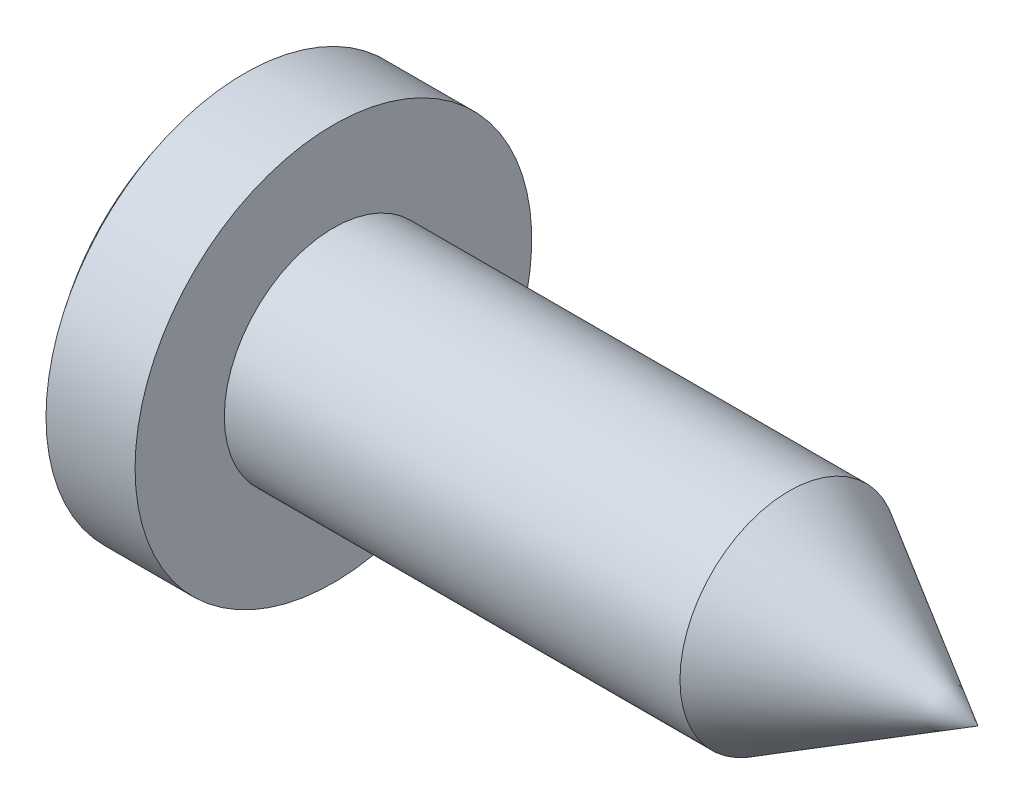
from build123d import *

# Parameters (mm, degrees)
CHAMFER1_SIZE      = 0.22
CHAMFER1_SIZE2     = 0.381051178
CUT_EXTRUDE1_DEPTH = 0.85
CUT_EXTRUDE1_TAPER = 6


with BuildPart() as part:
    # Sketch1 → Revolve1 (revolve)
    with BuildSketch(Plane.XY):
        with BuildLine():
            Line((0, 2), (-0.897999199, 2))
            ThreePointArc((-0.897999199, 2), (-1.419403703, 1.059811908), (-1.6, 0))
            Line((-1.6, 0), (6.5, 0))
            Line((6.5, 0), (6.5, 1.1))
            Line((6.5, 1.1), (0, 1.1))
            Line((0, 1.1), (0, 2))
        make_face()
    revolve(axis=Axis((0, 0, 0), (1, 0, 0)))

    # Chamfer1
    chamfer1_edges = [part.edges().sort_by_distance(p)[0] for p in [
        (6.5, -1.1, 0),
    ]]
    chamfer1_side = [part.faces().sort_by_distance(p)[0] for p in [
        (6.5, 0, 0),
    ]]
    chamfer(chamfer1_edges, length=CHAMFER1_SIZE, length2=CHAMFER1_SIZE2, reference=chamfer1_side[0])

    # Sketch2 → EndCone (revolve, cut)
    with BuildSketch(Plane.XY):
        Polygon((6.5, 0), (4.594744112, 1.1), (4.594744112, 1.2), (6.6, 1.2), (6.6, 0), align=None)
    revolve(axis=Axis((0, 0, 0), (1, 0, 0)), mode=Mode.SUBTRACT)

    # Sketch3 → Cut-Extrude1 (cut)
    with BuildSketch(Plane(origin=(-1.6, 0, 0), x_dir=(0, 0, -1), z_dir=(1, 0, 0))):
        Polygon((-0.2375, 0.95), (-0.1425, 0.57), (-0.29897586, 0.29897586), (-0.57, 0.1425), (-0.95, 0.2375), (-0.95, -0.2375), (-0.57, -0.1425), (-0.29897586, -0.29897586), (-0.1425, -0.57), (-0.2375, -0.95), (0.2375, -0.95), (0.1425, -0.57), (0.29897586, -0.29897586), (0.57, -0.1425), (0.95, -0.2375), (0.95, 0.2375), (0.57, 0.1425), (0.29897586, 0.29897586), (0.1425, 0.57), (0.2375, 0.95), align=None)
    extrude(amount=CUT_EXTRUDE1_DEPTH, taper=CUT_EXTRUDE1_TAPER, mode=Mode.SUBTRACT)


solid = part.part
